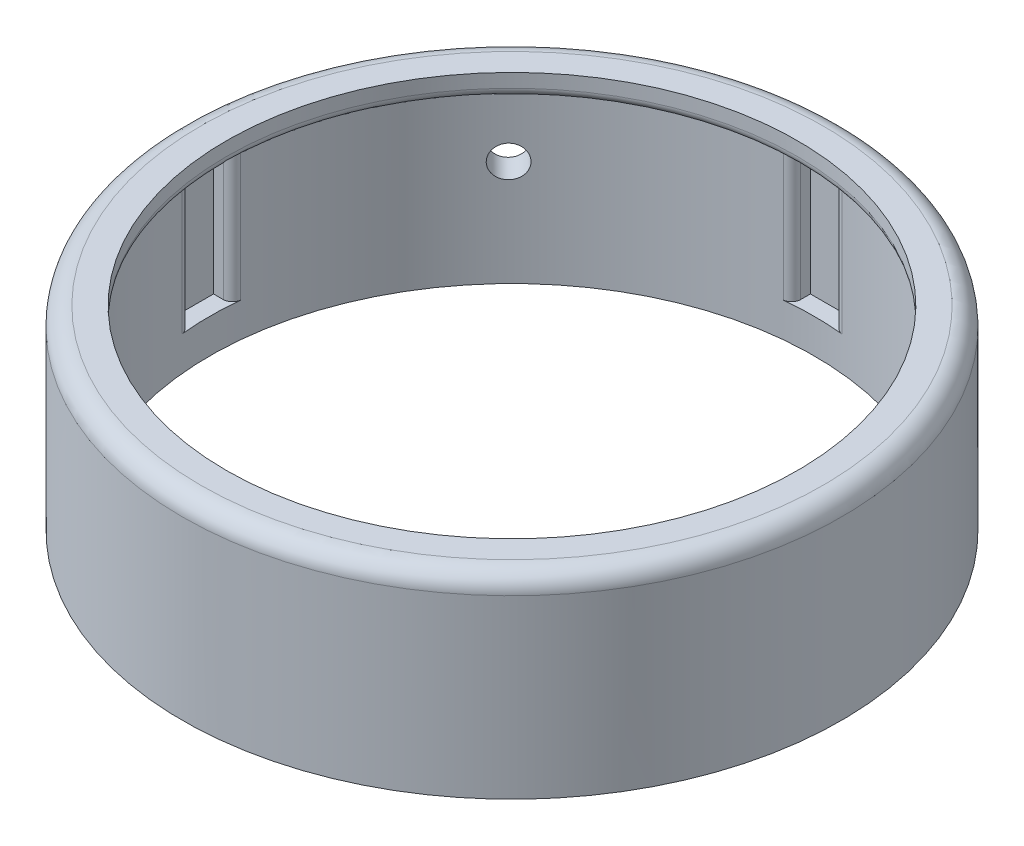
from build123d import *

# Parameters (mm, degrees)
SKETCH1_R                       = 45.72
BOSS_EXTRUDE1_DEPTH             = 22.225
SKETCH6_R                       = 39.624
CUT_EXTRUDE1_DEPTH              = 23.225
SKETCH8_R                       = 41.91
CUT_EXTRUDE2_DEPTH              = 19.05
FILLET1_R                       = 2.54
F_17_0_173_DIAMETER_HOLE2_D     = 4.3942
F_17_0_173_DIAMETER_HOLE2_DEPTH = 22.745829939
SKETCH25_W                      = 88.646
SKETCH25_H                      = 5.842
CUT_EXTRUDE7_DEPTH              = 19.05
SKETCH27_W                      = 5.842
SKETCH27_H                      = 88.646
CUT_EXTRUDE8_DEPTH              = 19.05
FILLET2_R                       = 1.27
FILLET3_R                       = 1.27
SKETCH36_R                      = 45.72
BOSS_EXTRUDE4_DEPTH             = 4.7625
SKETCH37_R                      = 41.91
CUT_EXTRUDE11_DEPTH             = 4.7625


with BuildPart() as part:
    # Sketch1 → Boss-Extrude1 (new body)
    with BuildSketch(Plane(origin=(0, 0, 0), x_dir=(1, 0, 0), z_dir=(0, 1, 0))):
        Circle(SKETCH1_R)
    extrude(amount=BOSS_EXTRUDE1_DEPTH)

    # Sketch6 → Cut-Extrude1 (cut, through all)
    with BuildSketch(Plane(origin=(0, 22.225, 0), x_dir=(1, 0, 0), z_dir=(0, 1, 0))):
        Circle(SKETCH6_R)
    extrude(amount=-CUT_EXTRUDE1_DEPTH, mode=Mode.SUBTRACT)

    # Sketch8 → Cut-Extrude2 (cut)
    with BuildSketch(Plane.XZ):
        Circle(SKETCH8_R)
    extrude(amount=-CUT_EXTRUDE2_DEPTH, mode=Mode.SUBTRACT)

    # Fillet1
    fillet1_edges = [part.edges().sort_by_distance(p)[0] for p in [
        (-45.72, 22.225, 0),
    ]]
    fillet(fillet1_edges, radius=FILLET1_R)

    # #17 (0.173) Diameter Hole2
    with Locations(Plane(origin=(-29.867831461, 9.910321026, -29.40001265), x_dir=(-0.701503523, 0, 0.712665986), z_dir=(0.712665986, 0, 0.701503523))):
        with Locations((0, 0)):
            Hole(F_17_0_173_DIAMETER_HOLE2_D / 2, depth=F_17_0_173_DIAMETER_HOLE2_DEPTH)

    # Sketch25 → Cut-Extrude7 (cut)
    with BuildSketch(Plane.XZ):
        Rectangle(SKETCH25_W, SKETCH25_H)
    extrude(amount=-CUT_EXTRUDE7_DEPTH, mode=Mode.SUBTRACT)

    # Sketch27 → Cut-Extrude8 (cut)
    with BuildSketch(Plane.XZ):
        Rectangle(SKETCH27_W, SKETCH27_H)
    extrude(amount=-CUT_EXTRUDE8_DEPTH, mode=Mode.SUBTRACT)

    # Fillet2
    fillet2_edges = [part.edges().sort_by_distance(p)[0] for p in [
        (41.808083656, 9.525, 2.921),
        (-41.808083656, 9.525, 2.921),
        (41.808083656, 9.525, -2.921),
        (-41.808083656, 9.525, -2.921),
        (2.921, 9.525, 41.808083656),
        (-2.921, 9.525, 41.808083656),
        (-2.921, 9.525, -41.808083656),
        (2.921, 9.525, -41.808083656),
    ]]
    fillet(fillet2_edges, radius=FILLET2_R)

    # Fillet3
    fillet3_edges = [part.edges().sort_by_distance(p)[0] for p in [
        (-39.624, 19.05, 0),
    ]]
    fillet(fillet3_edges, radius=FILLET3_R)

    # Sketch36 → Boss-Extrude4 (add)
    with BuildSketch(Plane.XZ):
        Circle(SKETCH36_R)
    extrude(amount=BOSS_EXTRUDE4_DEPTH)

    # Sketch37 → Cut-Extrude11 (cut)
    with BuildSketch(Plane(origin=(0, 0, 0), x_dir=(1, 0, 0), z_dir=(0, 1, 0))):
        Circle(SKETCH37_R)
    extrude(amount=-CUT_EXTRUDE11_DEPTH, mode=Mode.SUBTRACT)


solid = part.part
